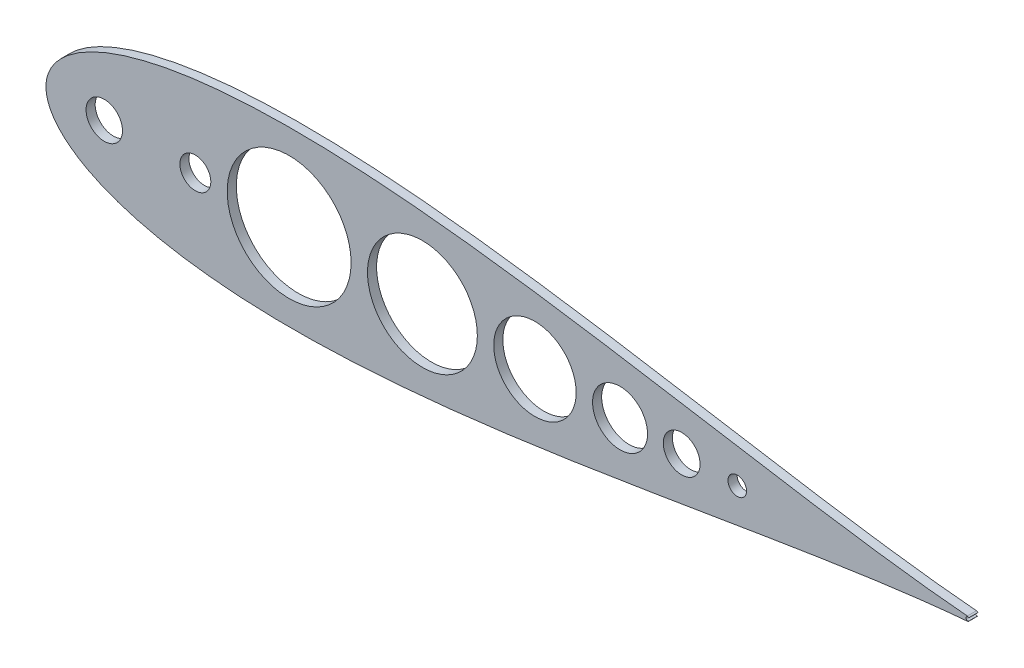
from build123d import *

# Parameters (mm, degrees)
BOSS_EXTRUDE1_DEPTH = 6.35
CUT_EXTRUDE2_START  = -7.3500001
CUT_EXTRUDE2_DEPTH  = 8.3500002


with BuildPart() as part:
    # Sketch2 → Boss-Extrude1 (new body)
    with BuildSketch(Plane.XY):
        with BuildLine():
            ThreePointArc((642.510849283, -1.582039112), (643.111845681, -1.408373102), (643.599082689, -1.016))
            ThreePointArc((643.599082689, -1.016), (642.269121423, -1.135922533), (641.567082689, 0))
            Line((641.567082689, 0), (473.360965279, 0))
            Line((473.360965279, 0), (460.660965279, 0))
            Line((460.660965279, 0), (114.935, 0))
            ThreePointArc((114.935, 0), (104.14, -10.795), (93.345, 0))
            Line((93.345, 0), (53.34, 0))
            ThreePointArc((53.34, 0), (40.64, -12.7), (27.94, 0))
            Line((27.94, 0), (0, 0))
            add(Edge.make_bspline(
                [(0, 0), (0, -1.007496172), (0.154611582, -3.513796615), (1.106333228, -7.923389435), (3.463136343, -13.420354421), (7.689616489, -19.513207632), (13.932423524, -25.726412106), (22.129107375, -31.731455339), (32.141645239, -37.332204029), (43.82045433, -42.41500246), (57.023709725, -46.912543066), (71.619696083, -50.784752003), (87.485018636, -54.008935199), (104.502313427, -56.574303932), (122.558104573, -58.481758104), (141.542033828, -59.739895824), (161.345829027, -60.366961324), (181.863132616, -60.387506142), (202.989192599, -59.8341217), (224.620860897, -58.745176641), (246.65655865, -57.164603829), (268.996310773, -55.141201012), (291.541767704, -52.727712704), (314.196207315, -49.979843895), (336.86454415, -46.955447457), (359.453314895, -43.713502532), (381.870662856, -40.313266856), (404.02631566, -36.813220545), (425.831595832, -33.270324121), (447.199424328, -29.739007432), (468.044367735, -26.27043606), (488.282710288, -22.911672601), (507.832591566, -19.705111663), (526.614143658, -16.687720753), (544.549749946, -13.890665375), (561.564270734, -11.338919625), (577.585454095, -9.050636147), (592.543922516, -7.037634907), (606.374988512, -5.304428983), (619.014124193, -3.849253664), (630.413817462, -2.663385493), (638.093728429, -1.953546407), (641.993392355, -1.625070631), (642.510849283, -1.582039112)],
                knots=[0.5, 0.5, 0.5, 0.5, 0.502166769, 0.505390167, 0.509655974, 0.514947682, 0.521244711, 0.528520886, 0.536744945, 0.54588136, 0.555890751, 0.566730119, 0.57835299, 0.590709588, 0.603747039, 0.617409572, 0.631638768, 0.646373793, 0.661551658, 0.677107483, 0.692974771, 0.709085713, 0.725371443, 0.741762353, 0.758188398, 0.774579367, 0.790865214, 0.806976332, 0.822843867, 0.838400002, 0.853578262, 0.868313774, 0.882543568, 0.896206835, 0.909245173, 0.92160287, 0.933227116, 0.944068236, 0.954079898, 0.963219316, 0.971447445, 0.978729112, 0.979842958, 0.979842958, 0.979842958, 0.979842958], degree=3))
        make_face()
    boss_extrude1 = extrude(amount=BOSS_EXTRUDE1_DEPTH)

    # Sketch3 → Cut-Extrude2 (cut)
    with BuildSketch(Plane.XY.offset(6.35).offset(CUT_EXTRUDE2_START)):
        with BuildLine():
            ThreePointArc((212.767950148, 0), (169.566475074, 43.201475074), (126.365, 0))
            Line((126.365, 0), (212.767950148, 0))
        make_face()
        with BuildLine():
            Line((212.767950148, 0), (126.365, 0))
            ThreePointArc((126.365, 0), (169.566475074, -43.201475074), (212.767950148, 0))
        make_face()
        with BuildLine():
            ThreePointArc((300.809151759, 0), (262.503550953, 38.305600806), (224.197950148, 0))
            Line((224.197950148, 0), (300.809151759, 0))
        make_face()
        with BuildLine():
            Line((300.809151759, 0), (224.197950148, 0))
            ThreePointArc((224.197950148, 0), (262.503550953, -38.305600806), (300.809151759, 0))
        make_face()
        with BuildLine():
            ThreePointArc((369.720663748, 0), (340.979907754, 28.740755995), (312.239151759, 0))
            Line((312.239151759, 0), (369.720663748, 0))
        make_face()
        with BuildLine():
            Line((369.720663748, 0), (312.239151759, 0))
            ThreePointArc((312.239151759, 0), (340.979907754, -28.740755995), (369.720663748, 0))
        make_face()
        with BuildLine():
            ThreePointArc((381.150663748, 0), (400.327663748, -19.177), (419.504663748, 0))
            Line((419.504663748, 0), (381.150663748, 0))
        make_face()
        with BuildLine():
            Line((381.150663748, 0), (419.504663748, 0))
            ThreePointArc((419.504663748, 0), (400.327663748, 19.177), (381.150663748, 0))
        make_face()
        with BuildLine():
            ThreePointArc((430.474866123, 0), (443.301866123, -12.827), (456.128866123, 0))
            Line((456.128866123, 0), (430.474866123, 0))
        make_face()
        with BuildLine():
            Line((430.474866123, 0), (456.128866123, 0))
            ThreePointArc((456.128866123, 0), (443.301866123, 12.827), (430.474866123, 0))
        make_face()
        with BuildLine():
            ThreePointArc((475.605534569, 0), (482.082534569, -6.477), (488.559534569, 0))
            Line((488.559534569, 0), (475.605534569, 0))
        make_face()
        with BuildLine():
            Line((475.605534569, 0), (488.559534569, 0))
            ThreePointArc((488.559534569, 0), (482.082534569, 6.477), (475.605534569, 0))
        make_face()
    cut_extrude2 = extrude(amount=CUT_EXTRUDE2_DEPTH, mode=Mode.SUBTRACT)

    # Mirror1: Boss-Extrude1, Cut-Extrude2 across plane
    add(boss_extrude1.mirror(Plane.ZX))
    add(cut_extrude2.mirror(Plane.ZX), mode=Mode.SUBTRACT)


solid = part.part
